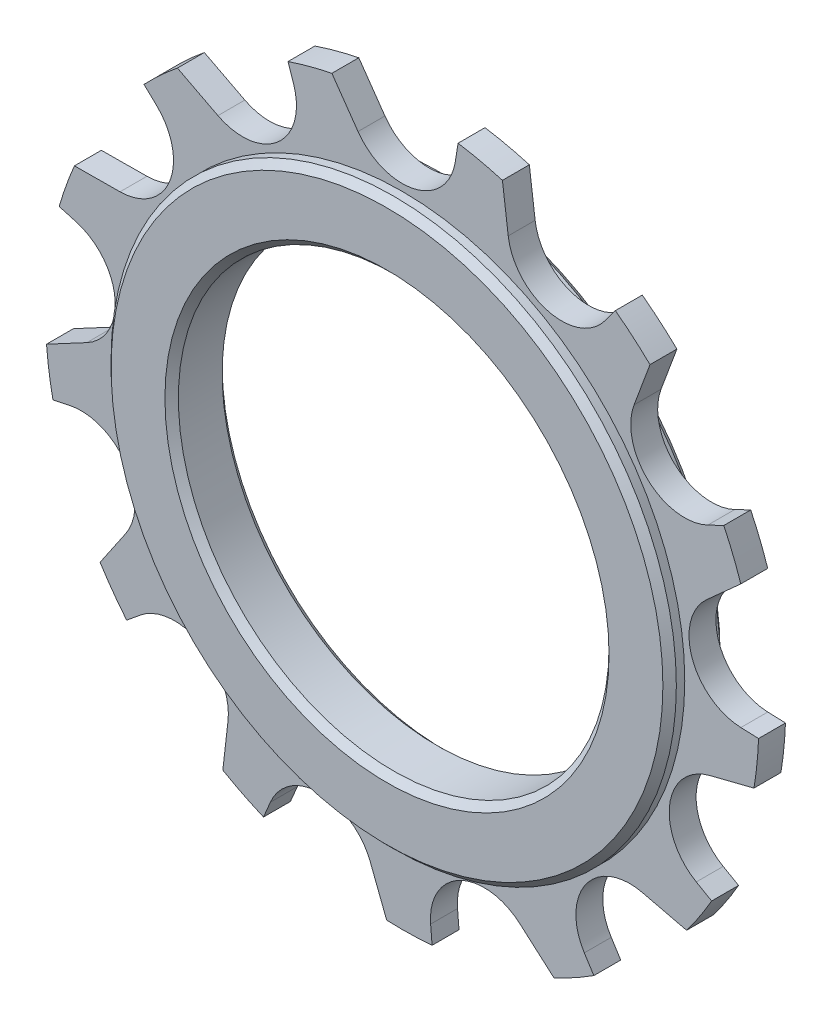
from build123d import *

# Parameters (mm, degrees)
ESQUISSE1_R                  = 26.5
EXTRUSION1_DEPTH             = 1
ENL_V_MAT_EXTRU_1_DEPTH      = 2
R_P_TITION_CIRCULAIRE1_COUNT = 13
ESQUISSE3_R                  = 21
EXTRUSION2_DEPTH             = 2.125
ESQUISSE4_R                  = 16
ENL_V_MAT_EXTRU_2_DEPTH      = 3.125
ENL_V_MAT_EXTRU_2_DEPTH_BACK = 3.125
CHANFREIN1_SIZE              = 0.5


with BuildPart() as part:
    # Esquisse1 → Extrusion1 (new body, symmetric)
    with BuildSketch(Plane.XY):
        Circle(ESQUISSE1_R)
    extrude(amount=EXTRUSION1_DEPTH, both=True)

    # Esquisse2 → Enlèv. mat.-Extru.1 (cut, symmetric)
    with BuildSketch(Plane.XY):
        with BuildLine():
            Line((-5.219783613, 25.98083638), (-3.276608177, 23.205694255))
            ThreePointArc((-3.276608177, 23.205694255), (0.898959157, 21.60232474), (3.95048165, 24.87254902))
            Line((3.95048165, 24.87254902), (4.156862745, 26.171940931))
            ThreePointArc((4.156862745, 26.171940931), (-0.53998188, 26.494497911), (-5.219783613, 25.98083638))
        make_face()
    enl_v_mat_extru_1 = extrude(amount=ENL_V_MAT_EXTRU_1_DEPTH, both=True, mode=Mode.SUBTRACT)

    # Répétition circulaire1: Enlèv. mat.-Extru.1 ×13 about axis
    r_p_tition_circulaire1_axis = Axis((0, 0, 0), (0, 0, 1))
    for i in range(1, R_P_TITION_CIRCULAIRE1_COUNT):
        add(enl_v_mat_extru_1.rotate(r_p_tition_circulaire1_axis, i * 360 / R_P_TITION_CIRCULAIRE1_COUNT), mode=Mode.SUBTRACT)

    # Esquisse3 → Extrusion2 (add, symmetric)
    with BuildSketch(Plane.XY):
        Circle(ESQUISSE3_R)
    extrude(amount=EXTRUSION2_DEPTH, both=True)

    # Esquisse4 → Enlèv. mat.-Extru.2 (cut, two sides)
    with BuildSketch(Plane.XY) as enl_v_mat_extru_2_sk:
        Circle(ESQUISSE4_R)
    extrude(amount=ENL_V_MAT_EXTRU_2_DEPTH, mode=Mode.SUBTRACT)
    extrude(enl_v_mat_extru_2_sk.sketch, amount=-ENL_V_MAT_EXTRU_2_DEPTH_BACK, mode=Mode.SUBTRACT)

    # Chanfrein1
    chanfrein1_edges = [part.edges().sort_by_distance(p)[0] for p in [
        (-21, 0, -2.125),
        (-21, 0, 2.125),
        (-16, 0, -2.125),
        (-16, 0, 2.125),
    ]]
    chamfer(chanfrein1_edges, length=CHANFREIN1_SIZE)


solid = part.part
